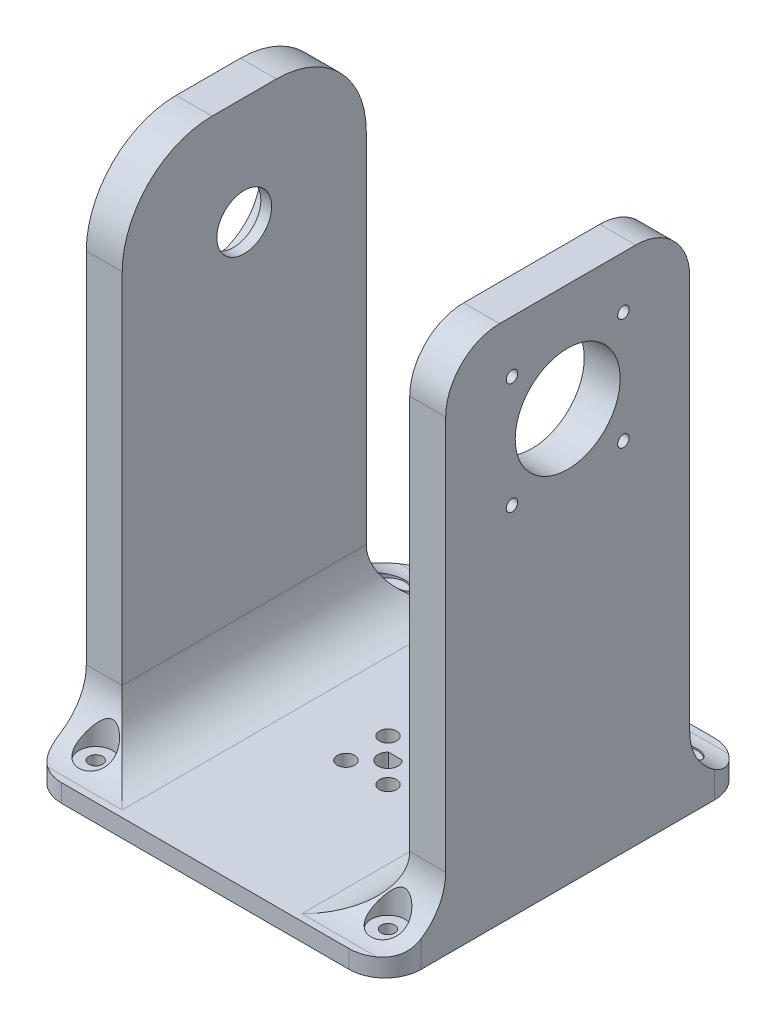
from build123d import *

# Parameters (mm, degrees)
SKETCH2_W             = 10
SKETCH2_H             = 101.6
BOSS_EXTRUDE1_DEPTH   = 139.7
BOSS_EXTRUDE1_2_DEPTH = 139.7
SKETCH2_3_W           = 10
SKETCH2_3_H           = 101.6
SKETCH2_3_W_2         = 80
BOSS_EXTRUDE2_DEPTH   = 5
SKETCH3_R             = 14.605
CUT_EXTRUDE1_DEPTH    = 117
SKETCH4_W             = 16.851782798
SKETCH4_H             = 139.7
CUT_EXTRUDE2_DEPTH    = 119
FILLET14_R            = 15
FILLET2_R             = 10
SKETCH7_R             = 1.6
CUT_EXTRUDE4_DEPTH    = 21
BOSS_EXTRUDE3_START   = 80
SKETCH8_R             = 14.75414129
SKETCH8_R_2           = 7.62
BOSS_EXTRUDE3_DEPTH   = 3
SKETCH9_R             = 1.905
CUT_EXTRUDE5_DEPTH    = 145.7
CUT_EXTRUDE6_DEPTH    = 10
FILLET4_R             = 25
SKETCH10_R            = 2.4003
CUT_EXTRUDE7_DEPTH    = 10
SKETCH11_R            = 4.7
CUT_EXTRUDE9_DEPTH    = 10
CHAMFER1_SIZE         = 1.778
SKETCH12_R            = 2.921
CUT_EXTRUDE10_DEPTH   = 3.302


with BuildPart() as part:
    # Sketch2 → Boss-Extrude1 (new body)
    with BuildSketch(Plane(origin=(0, 0, 0), x_dir=(1, 0, 0), z_dir=(0, 1, 0))):
        with Locations((-45, 0)):
            Rectangle(SKETCH2_W, SKETCH2_H)
    extrude(amount=BOSS_EXTRUDE1_DEPTH)



with BuildPart() as body_2:
    # Sketch2 → Boss-Extrude1 2 (new body)
    with BuildSketch(Plane(origin=(0, 0, 0), x_dir=(1, 0, 0), z_dir=(0, 1, 0))):
        with Locations((45, 0)):
            Rectangle(SKETCH2_W, SKETCH2_H)
    extrude(amount=BOSS_EXTRUDE1_2_DEPTH)


with BuildPart() as part_1:
    add(part.part)

    add(body_2.part)  # Boss-Extrude2 merges body 2
    # Sketch2_3 → Boss-Extrude2 (add)
    with BuildSketch(Plane(origin=(0, 0, 0), x_dir=(1, 0, 0), z_dir=(0, 1, 0))):
        with Locations((45, 0)):
            Rectangle(SKETCH2_3_W, SKETCH2_3_H)
        Rectangle(SKETCH2_3_W_2, SKETCH2_3_H)
        with Locations((-45, 0)):
            Rectangle(SKETCH2_3_W, SKETCH2_3_H)
    extrude(amount=-BOSS_EXTRUDE2_DEPTH)

    # Sketch3 → Cut-Extrude1 (cut)
    with BuildSketch(Plane.ZY.offset(50)):
        with Locations((0, 109.7)):
            Circle(SKETCH3_R)
    extrude(amount=-CUT_EXTRUDE1_DEPTH, mode=Mode.SUBTRACT)

    # Sketch4 → Cut-Extrude2 (cut)
    with BuildSketch(Plane(origin=(50, 0, 0), x_dir=(0, 0, -1), z_dir=(1, 0, 0))):
        with Locations((-42.374108601, 69.85)):
            Rectangle(SKETCH4_W, SKETCH4_H)
        with Locations((42.374108601, 69.85)):
            Rectangle(SKETCH4_W, SKETCH4_H)
    extrude(amount=-CUT_EXTRUDE2_DEPTH, mode=Mode.SUBTRACT)

    # Fillet14
    fillet14_edges = [part_1.edges().sort_by_distance(p)[0] for p in [
        (45, 139.7, -33.948217202),
        (45, 139.7, 33.948217202),
        (40, 0, 0),
        (-40, 0, 0),
        (-45, 0, 33.948217202),
        (45, 0, 33.948217202),
        (-45, 0, -33.948217202),
        (45, 0, -33.948217202),
    ]]
    fillet(fillet14_edges, radius=FILLET14_R)

    # Fillet2
    fillet2_edges = [part_1.edges().sort_by_distance(p)[0] for p in [
        (50, -2.5, -50.8),
        (-50, -2.5, -50.8),
        (50, -2.5, 50.8),
        (-50, -2.5, 50.8),
    ]]
    fillet(fillet2_edges, radius=FILLET2_R)

    # Sketch7 → Cut-Extrude4 (cut)
    with BuildSketch(Plane(origin=(50, 0, 0), x_dir=(0, 0, -1), z_dir=(1, 0, 0))):
        with Locations((-15.5, 125.2)):
            Circle(SKETCH7_R)
        with Locations((15.5, 125.2)):
            Circle(SKETCH7_R)
        with Locations((15.5, 94.2)):
            Circle(SKETCH7_R)
        with Locations((-15.5, 94.2)):
            Circle(SKETCH7_R)
    extrude(amount=-CUT_EXTRUDE4_DEPTH, mode=Mode.SUBTRACT)

    # Sketch8 → Boss-Extrude3 (add)
    with BuildSketch(Plane.ZY.offset(-40).offset(BOSS_EXTRUDE3_START)):
        with Locations((0, 109.7)):
            Circle(SKETCH8_R)
        with Locations((0, 109.7)):
            Circle(SKETCH8_R_2, mode=Mode.SUBTRACT)
    extrude(amount=BOSS_EXTRUDE3_DEPTH)

    # Sketch9 → Cut-Extrude5 (cut, through all)
    with BuildSketch(Plane.XZ.offset(5)):
        with Locations((-40.66, 40.66)):
            Circle(SKETCH9_R)
        with Locations((40.66, 40.66)):
            Circle(SKETCH9_R)
        with Locations((-40.66, -40.66)):
            Circle(SKETCH9_R)
        with Locations((40.66, -40.66)):
            Circle(SKETCH9_R)
    extrude(amount=-CUT_EXTRUDE5_DEPTH, mode=Mode.SUBTRACT)

    # Sketch5 → Cut-Extrude6 (cut)
    with BuildSketch(Plane(origin=(0, 0, 0), x_dir=(1, 0, 0), z_dir=(0, 1, 0))):
        with BuildLine():
            Line((-1.917657947, 2.032), (1.917657947, 2.032))
            ThreePointArc((1.917657947, 2.032), (0, -2.794), (-1.917657947, 2.032))
        make_face()
    extrude(amount=-CUT_EXTRUDE6_DEPTH, mode=Mode.SUBTRACT)

    # Fillet4
    fillet4_edges = [part_1.edges().sort_by_distance(p)[0] for p in [
        (-45, 139.7, 33.948217202),
        (-45, 139.7, -33.948217202),
    ]]
    fillet(fillet4_edges, radius=FILLET4_R)

    # Sketch10 → Cut-Extrude7 (cut)
    with BuildSketch(Plane(origin=(0, 0, 0), x_dir=(1, 0, 0), z_dir=(0, 1, 0))):
        with Locations((-5.856308805, 5.856308805)):
            Circle(SKETCH10_R)
        with Locations((5.856308805, 5.856308805)):
            Circle(SKETCH10_R)
        with Locations((-5.856308805, -5.856308805)):
            Circle(SKETCH10_R)
        with Locations((5.856308805, -5.856308805)):
            Circle(SKETCH10_R)
    extrude(amount=-CUT_EXTRUDE7_DEPTH, mode=Mode.SUBTRACT)

    # Sketch11 → Cut-Extrude9 (cut)
    with BuildSketch(Plane(origin=(0, 0, 0), x_dir=(1, 0, 0), z_dir=(0, 1, 0))):
        with Locations((-40.66, -40.66)):
            Circle(SKETCH11_R)
        with Locations((40.66, -40.66)):
            Circle(SKETCH11_R)
        with Locations((-40.66, 40.66)):
            Circle(SKETCH11_R)
        with Locations((40.66, 40.66)):
            Circle(SKETCH11_R)
    extrude(amount=CUT_EXTRUDE9_DEPTH, mode=Mode.SUBTRACT)

    # Chamfer1
    chamfer1_edges = [part_1.edges().sort_by_distance(p)[0] for p in [
        (38.755, -5, 40.66),
        (-42.565, -5, -40.66),
        (38.755, -5, -40.66),
        (-42.565, -5, 40.66),
    ]]
    chamfer(chamfer1_edges, length=CHAMFER1_SIZE)

    # Sketch12 → Cut-Extrude10 (cut)
    with BuildSketch(Plane.ZY.offset(-40)):
        with Locations((-15.5, 125.2)):
            Circle(SKETCH12_R)
        with Locations((15.5, 125.2)):
            Circle(SKETCH12_R)
        with Locations((-15.5, 94.2)):
            Circle(SKETCH12_R)
        with Locations((15.5, 94.2)):
            Circle(SKETCH12_R)
    extrude(amount=-CUT_EXTRUDE10_DEPTH, mode=Mode.SUBTRACT)


solid = part_1.part
